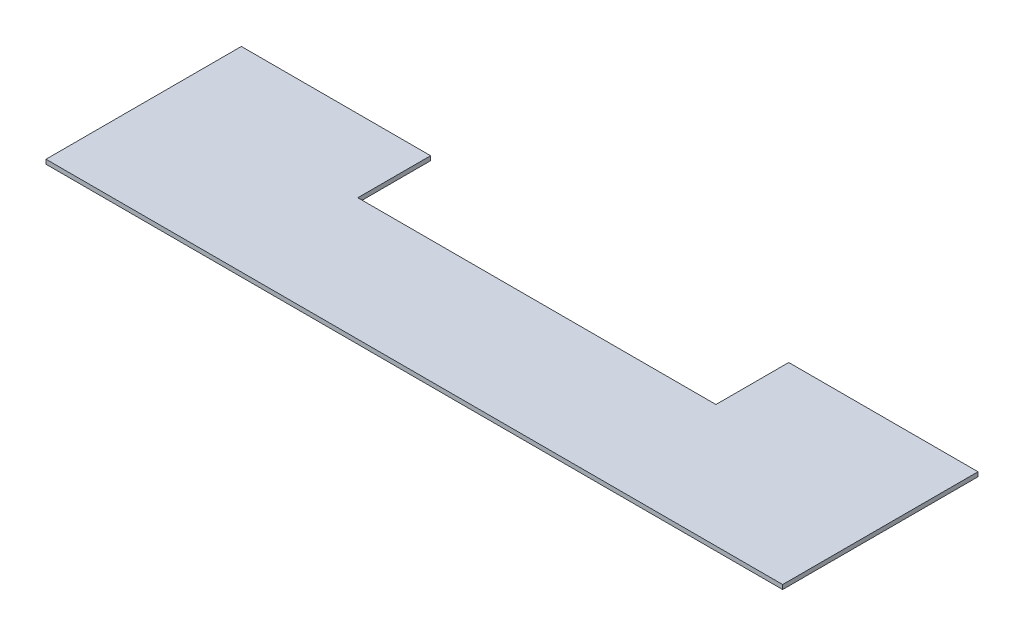
from build123d import *

# Parameters (mm, degrees)
BOSS_EXTRUDE1_DEPTH = 3


with BuildPart() as part:
    # Sketch1 → Boss-Extrude1 (new body)
    with BuildSketch(Plane(origin=(0, 0, 0), x_dir=(1, 0, 0), z_dir=(0, 1, 0))):
        Polygon((-297.333718436, 57.553572901), (-167.333718436, 57.553572901), (-167.333718436, 17.553572901), (-167.333718436, 7.553572901), (78.666281564, 7.553572901), (78.666281564, 17.553572901), (78.666281564, 57.553572901), (208.666281564, 57.553572901), (208.666281564, -76.627381996), (-297.333718436, -76.627381996), align=None)
    extrude(amount=BOSS_EXTRUDE1_DEPTH)


solid = part.part
